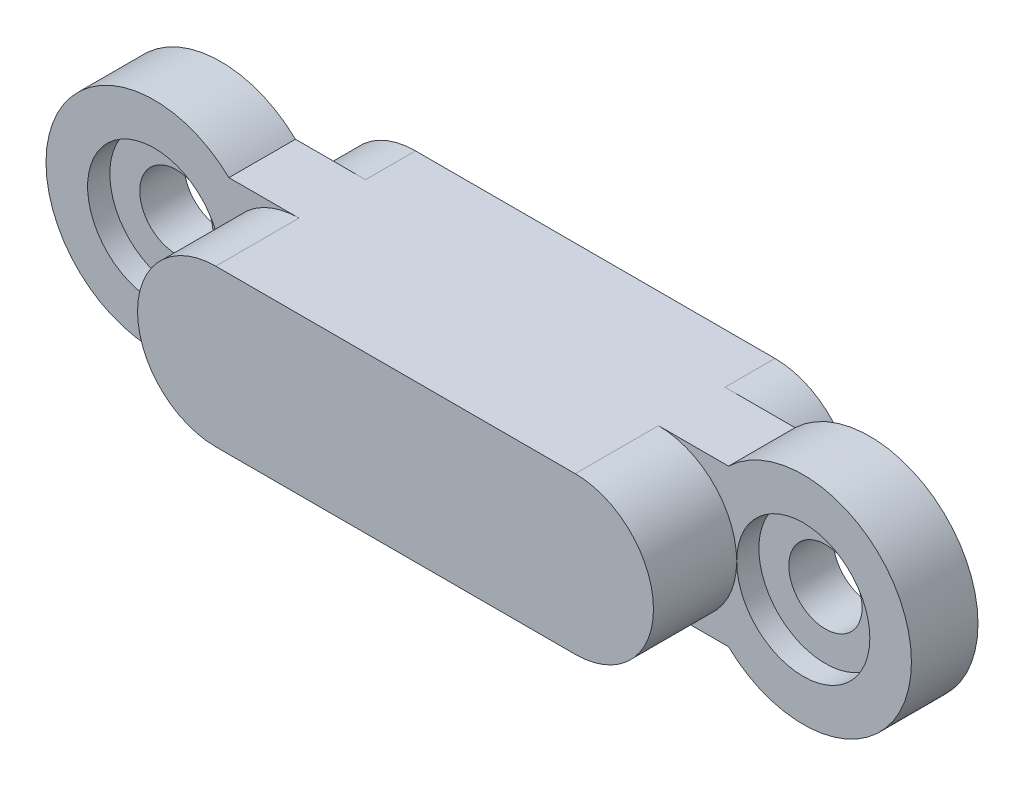
from build123d import *

# Parameters (mm, degrees)
EXTRUDE_4_DEPTH     = 2.5
SKETCH_5_R          = 1.1
EXTRUDE_5_DEPTH     = 2
SKETCH_6_R          = 2
CUT_EXTRUDE_1_DEPTH = 0.666666667
SKETCH_7_R          = 2.35
SKETCH_7_W          = 10.8
SKETCH_7_H          = 4.7
EXTRUDE_6_DEPTH     = 1.5
SKETCH_8_R          = 0.5
EXTRUDE_7_DEPTH     = 1.5


with BuildPart() as part:
    # Эскиз4 → Бобышка-Вытянуть4 (new body)
    with BuildSketch(Plane.XY.offset(1.9)):
        with BuildLine():
            ThreePointArc((0, 0), (-2.35, -2.35), (0, -4.7))
            Line((0, -4.7), (0, 0))
        make_face()
        with BuildLine():
            Line((0, 0), (0, -4.7))
            ThreePointArc((0, -4.7), (1.661700936, -4.011700936), (2.35, -2.35))
            ThreePointArc((2.35, -2.35), (1.661700936, -0.688299064), (0, 0))
        make_face()
        with BuildLine():
            ThreePointArc((2.35, -2.35), (1.661700936, -4.011700936), (0, -4.7))
            Line((0, -4.7), (10.8, -4.7))
            ThreePointArc((10.8, -4.7), (8.45, -2.35), (10.8, 0))
            Line((10.8, 0), (0, 0))
            ThreePointArc((0, 0), (1.661700936, -0.688299064), (2.35, -2.35))
        make_face()
        with BuildLine():
            ThreePointArc((10.8, 0), (8.45, -2.35), (10.8, -4.7))
            Line((10.8, -4.7), (10.8, 0))
        make_face()
        with BuildLine():
            Line((10.8, 0), (10.8, -4.7))
            ThreePointArc((10.8, -4.7), (12.461700936, -4.011700936), (13.15, -2.35))
            ThreePointArc((13.15, -2.35), (12.461700936, -0.688299064), (10.8, 0))
        make_face()
    extrude(amount=EXTRUDE_4_DEPTH)

    # Эскиз5 → Бобышка-Вытянуть5 (add)
    with BuildSketch(Plane(origin=(0, 0, 1.9), x_dir=(-1, 0, 0), z_dir=(0, 0, -1))):
        with BuildLine():
            ThreePointArc((-12.905005568, 0), (-18.4, -2.35), (-12.905005568, -4.7))
            Line((-12.905005568, -4.7), (2.105005568, -4.7))
            ThreePointArc((2.105005568, -4.7), (7.6, -2.35), (2.105005568, 0))
            Line((2.105005568, 0), (-12.905005568, 0))
        make_face()
        with Locations((-15.15, -2.35)):
            Circle(SKETCH_5_R, mode=Mode.SUBTRACT)
        with Locations((4.35, -2.35)):
            Circle(SKETCH_5_R, mode=Mode.SUBTRACT)
    extrude(amount=EXTRUDE_5_DEPTH)

    # Эскиз6 → Вырез-Вытянуть1 (cut)
    with BuildSketch(Plane.XY.offset(1.9)):
        with Locations((15.15, -2.35)):
            Circle(SKETCH_6_R)
        with Locations((-4.35, -2.35)):
            Circle(SKETCH_6_R)
    extrude(amount=-CUT_EXTRUDE_1_DEPTH, mode=Mode.SUBTRACT)

    # Эскиз7 → Бобышка-Вытянуть6 (add)
    with BuildSketch(Plane(origin=(0, 0, -0.1), x_dir=(-1, 0, 0), z_dir=(0, 0, -1))):
        with Locations((-10.8, -2.35)):
            Circle(SKETCH_7_R)
        with Locations((0, -2.35)):
            Circle(SKETCH_7_R)
        with Locations((-5.4, -2.35)):
            Rectangle(SKETCH_7_W, SKETCH_7_H)
    extrude(amount=EXTRUDE_6_DEPTH)

    # Эскиз8 → Бобышка-Вытянуть7 (add)
    with BuildSketch(Plane(origin=(0, 0, -1.6), x_dir=(-1, 0, 0), z_dir=(0, 0, -1))):
        with Locations((-5.4, -2.35)):
            Circle(SKETCH_8_R)
    extrude(amount=EXTRUDE_7_DEPTH)


solid = part.part
